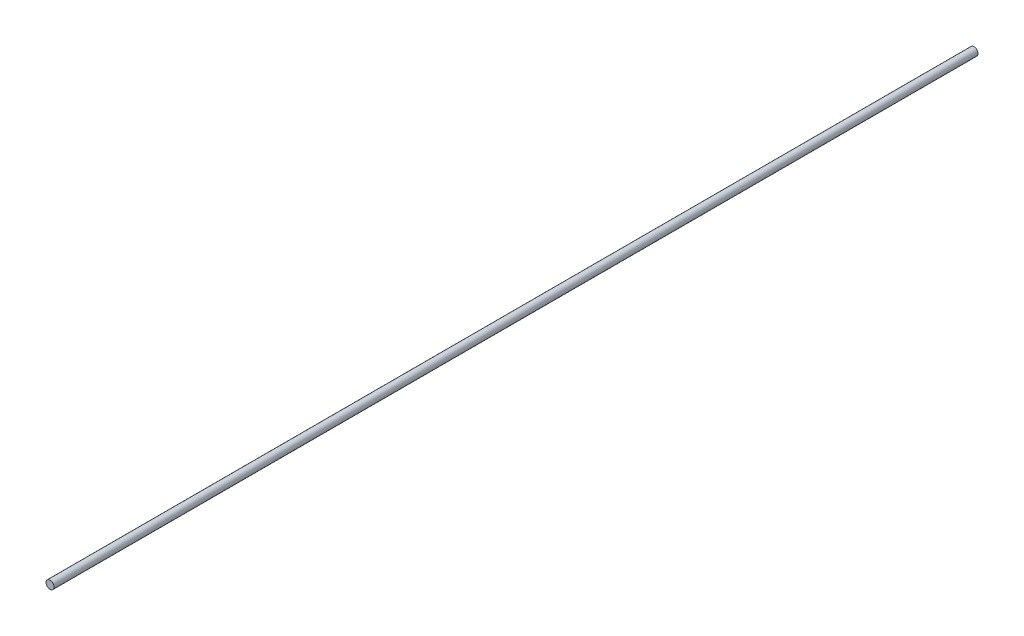
from build123d import *

# Parameters (mm, degrees)
SKETCH1_R           = 7.9375
BOSS_EXTRUDE1_DEPTH = 914.4


with BuildPart() as part:
    # Sketch1 → Boss-Extrude1 (new body, symmetric)
    with BuildSketch(Plane.XY):
        Circle(SKETCH1_R)
    extrude(amount=BOSS_EXTRUDE1_DEPTH, both=True)


solid = part.part
